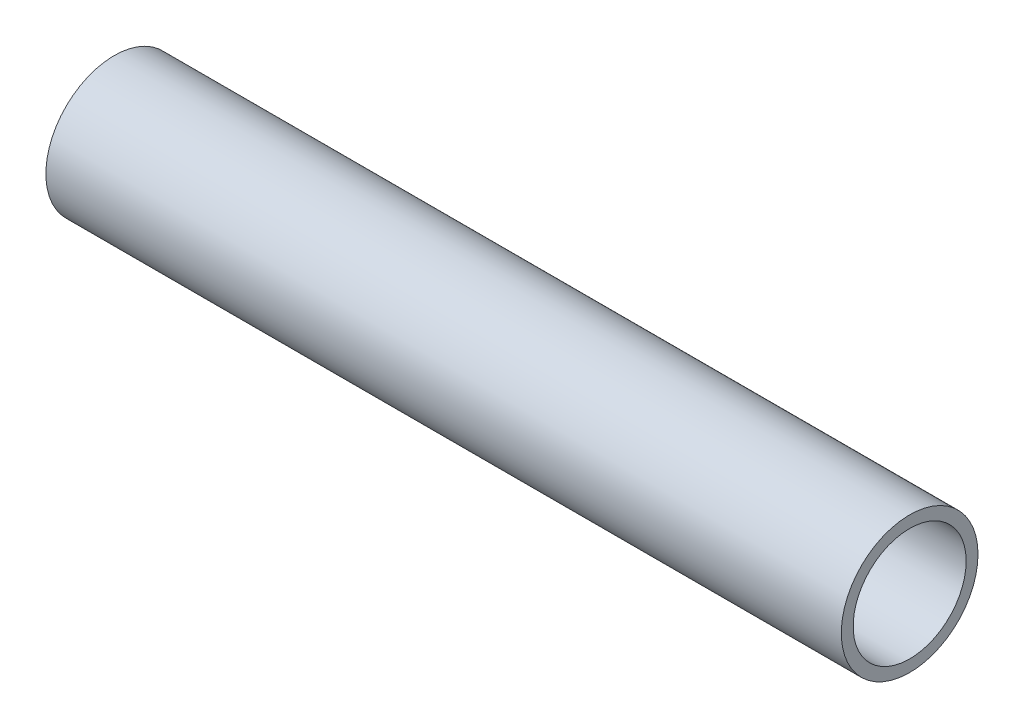
from build123d import *

# Parameters (mm, degrees)
SKETCH1_R           = 9.525
SKETCH1_R_2         = 7.874
BOSS_EXTRUDE1_DEPTH = 55.4228


with BuildPart() as part:
    # Sketch1 → Boss-Extrude1 (new body, symmetric)
    with BuildSketch(Plane(origin=(0, 0, 0), x_dir=(0, 0, -1), z_dir=(1, 0, 0))):
        Circle(SKETCH1_R)
        Circle(SKETCH1_R_2, mode=Mode.SUBTRACT)
    extrude(amount=BOSS_EXTRUDE1_DEPTH, both=True)


solid = part.part
